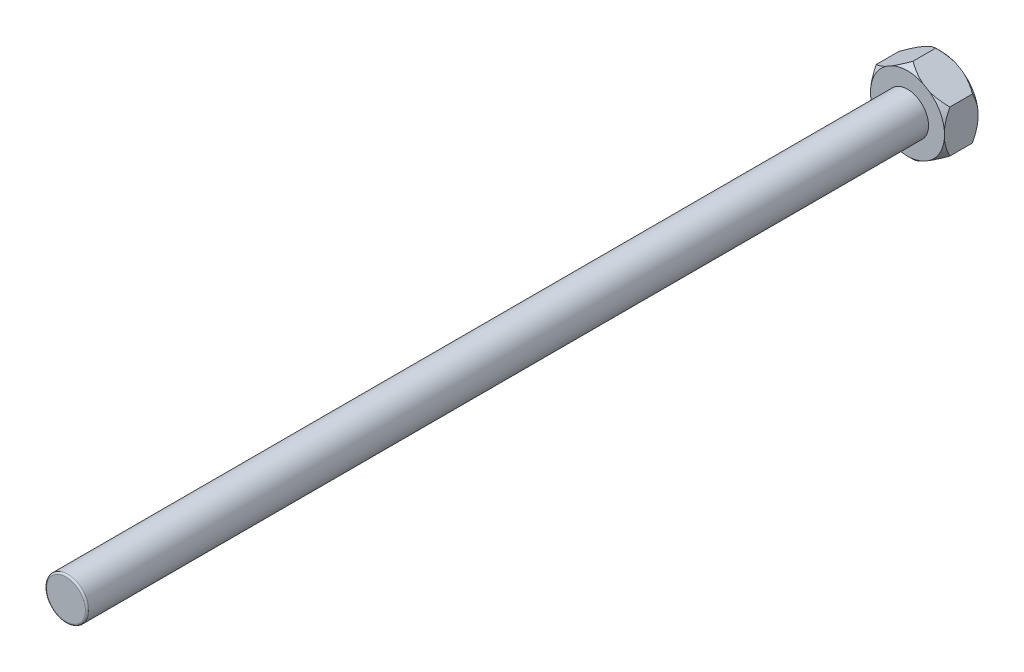
from build123d import *

# Parameters (mm, degrees)
EXTRUDE_1_DEPTH = 3.2
SKETCH_2_R      = 2
EXTRUDE_2_DEPTH = 80
FILLET_1_R      = 0.16


with BuildPart() as part:
    # 草图1 → 凸台-拉伸1 (new body)
    with BuildSketch(Plane.XY):
        Polygon((0, 4.041451884), (-3.5, 2.020725942), (-3.5, -2.020725942), (0, -4.041451884), (3.5, -2.020725942), (3.5, 2.020725942), align=None)
    extrude(amount=-EXTRUDE_1_DEPTH)

    # 草图3 → 切除-旋转1 (revolve, cut)
    with BuildSketch(Plane(origin=(0, 0, 0), x_dir=(0, 0, -1), z_dir=(1, 0, 0))):
        Polygon((0.523, 4.041451884), (0, 3.518451884), (0, 4.041451884), align=None)
        Polygon((3.2, 4.041451884), (3.2, 3.518451884), (2.677, 4.041451884), align=None)
    revolve(axis=Axis((0, 0, 0), (0, 0, 1)), mode=Mode.SUBTRACT)

    # 草图2 → 凸台-拉伸2 (add)
    with BuildSketch(Plane.XY):
        Circle(SKETCH_2_R)
    extrude(amount=EXTRUDE_2_DEPTH)

    # 圆角1
    fillet_1_edges = [part.edges().sort_by_distance(p)[0] for p in [
        (-2, 0, 80),
    ]]
    fillet(fillet_1_edges, radius=FILLET_1_R)


solid = part.part
